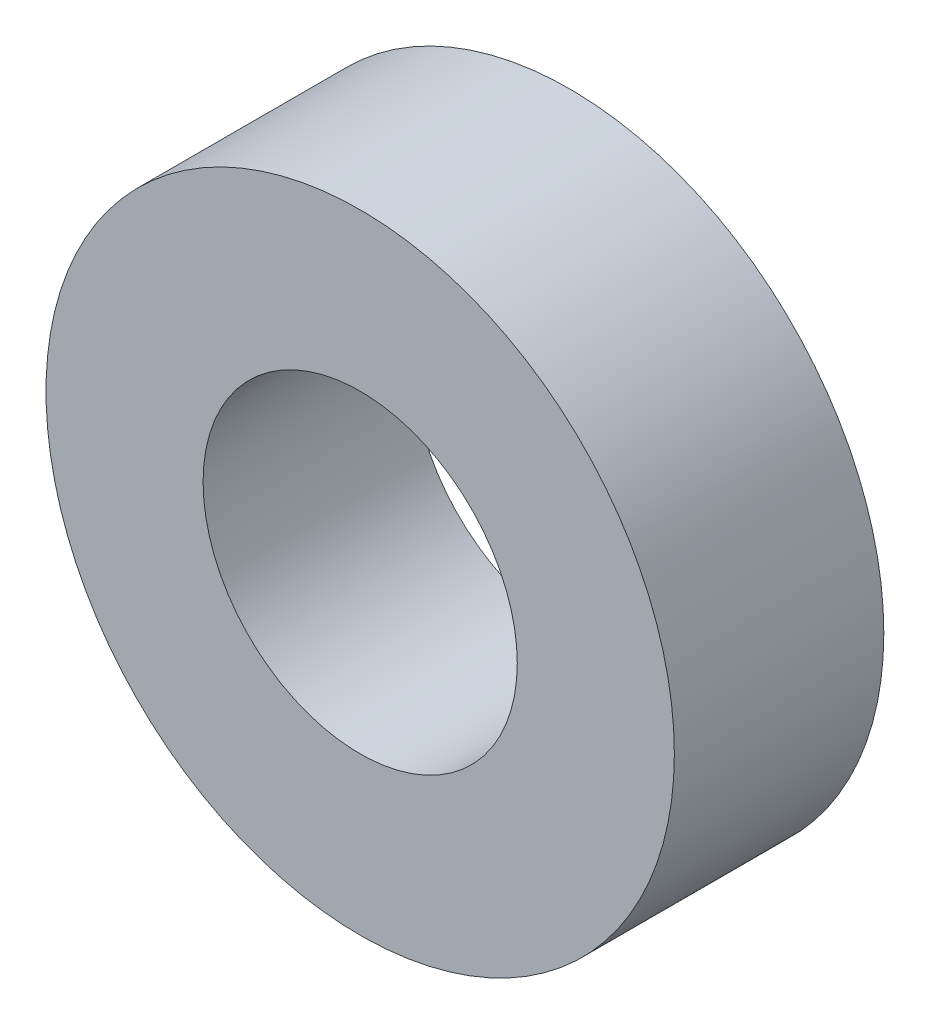
from build123d import *

# Parameters (mm, degrees)
SKETCH_1_R      = 6
SKETCH_1_R_2    = 3
EXTRUDE_1_DEPTH = 4


with BuildPart() as part:
    # 草图1 → 凸台-拉伸1 (new body)
    with BuildSketch(Plane.XY):
        with Locations((0, 0.831751318)):
            Circle(SKETCH_1_R)
        with Locations((0, 0.831751318)):
            Circle(SKETCH_1_R_2, mode=Mode.SUBTRACT)
    extrude(amount=EXTRUDE_1_DEPTH)


solid = part.part
